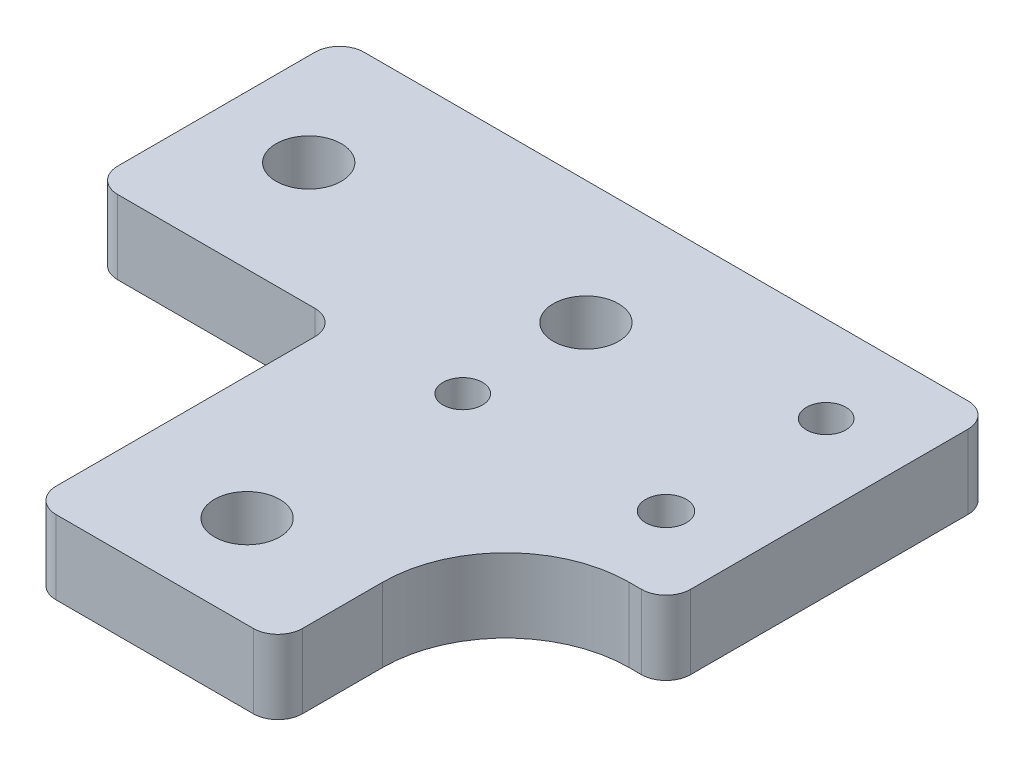
from build123d import *

# Parameters (mm, degrees)
SKETCH1_R           = 1.65
SKETCH1_R_2         = 1.6
SKETCH1_R_3         = 2.65
BOSS_EXTRUDE1_DEPTH = 6


with BuildPart() as part:
    # Sketch1 → Boss-Extrude1 (new body)
    with BuildSketch(Plane(origin=(0, 6, 0), x_dir=(1, 0, 0), z_dir=(0, 1, 0))):
        with BuildLine():
            Line((104, 0), (55, 0))
            ThreePointArc((55, 0), (53.585786438, -0.585786438), (53, -2))
            Line((53, -2), (53, -18))
            ThreePointArc((53, -18), (53.585786438, -19.414213562), (55, -20))
            Line((55, -20), (71, -20))
            ThreePointArc((71, -20), (72.414213562, -20.585786438), (73, -22))
            Line((73, -22), (73, -43))
            ThreePointArc((73, -43), (73.585786438, -44.414213562), (75, -45))
            Line((75, -45), (91, -45))
            ThreePointArc((91, -45), (92.414213562, -44.414213562), (93, -43))
            Line((93, -43), (93, -36.5))
            ThreePointArc((93, -36.5), (95.928932188, -29.428932188), (103, -26.5))
            Line((103, -26.5), (104, -26.5))
            ThreePointArc((104, -26.5), (105.414213562, -25.914213562), (106, -24.5))
            Line((106, -24.5), (106, -2))
            ThreePointArc((106, -2), (105.414213562, -0.585786438), (104, 0))
        make_face()
        with Locations((99.5, -20)):
            Circle(SKETCH1_R, mode=Mode.SUBTRACT)
        with Locations((99.5, -7)):
            Circle(SKETCH1_R_2, mode=Mode.SUBTRACT)
        with Locations((83, -20)):
            Circle(SKETCH1_R_2, mode=Mode.SUBTRACT)
        with Locations((83, -10)):
            Circle(SKETCH1_R_3, mode=Mode.SUBTRACT)
        with Locations((60.5, -10)):
            Circle(SKETCH1_R_3, mode=Mode.SUBTRACT)
        with Locations((83, -37.5)):
            Circle(SKETCH1_R_3, mode=Mode.SUBTRACT)
    extrude(amount=-BOSS_EXTRUDE1_DEPTH)


solid = part.part
